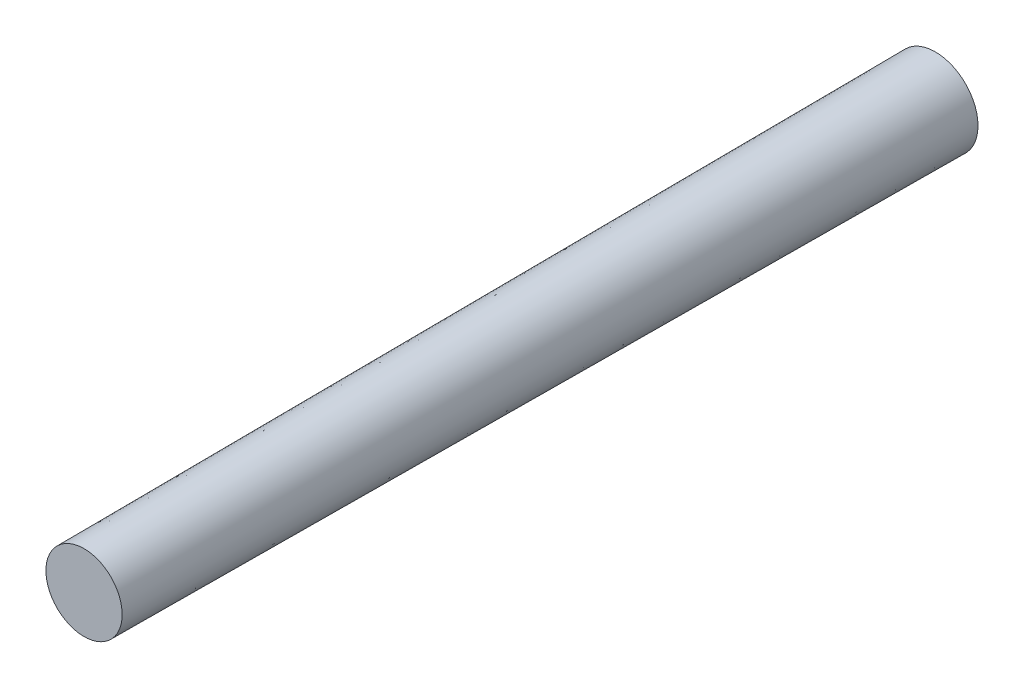
from build123d import *

# Parameters (mm, degrees)
SKETCH1_R           = 3
BOSS_EXTRUDE1_DEPTH = 60
BOSS_EXTRUDE1_TAPER = 0.3


with BuildPart() as part:
    # Sketch1 → Boss-Extrude1 (new body)
    with BuildSketch(Plane.XY):
        Circle(SKETCH1_R)
    extrude(amount=BOSS_EXTRUDE1_DEPTH, taper=BOSS_EXTRUDE1_TAPER)


solid = part.part
